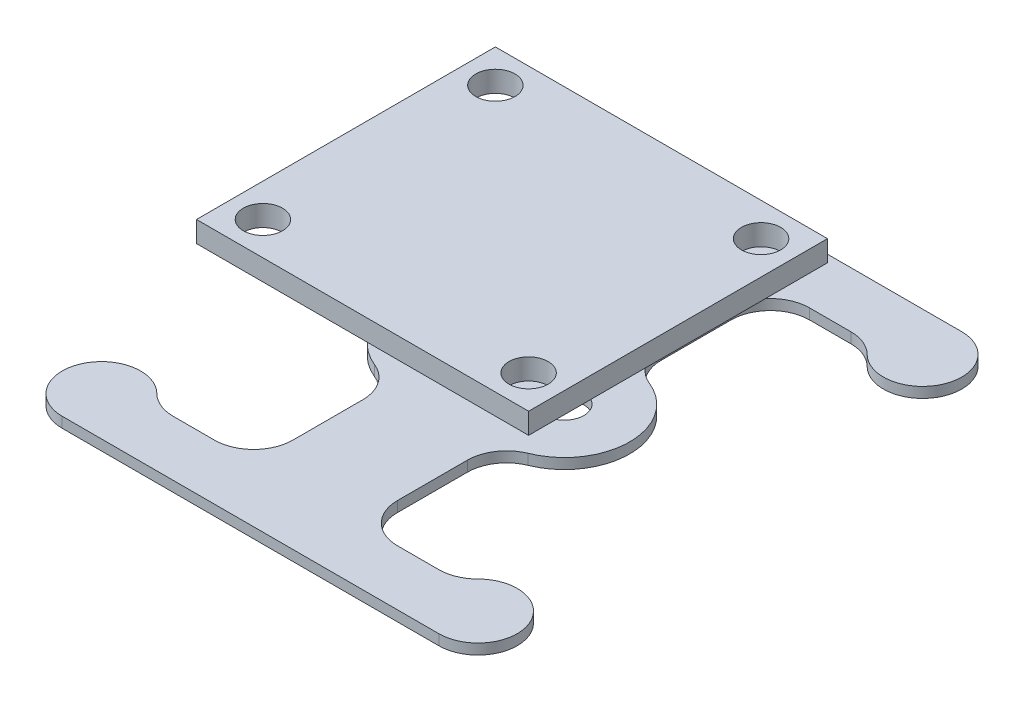
from build123d import *

# Parameters (mm, degrees)
SKETCH1_W           = 25.4
SKETCH1_H           = 22.86
SKETCH1_R           = 1.5
BOSS_EXTRUDE1_DEPTH = 1.6
SKETCH10_R          = 1.5
BOSS_EXTRUDE7_DEPTH = 0.8


with BuildPart() as part:
    # Sketch1 → Boss-Extrude1 (new body)
    with BuildSketch(Plane(origin=(0, 0, 0), x_dir=(1, 0, 0), z_dir=(0, 1, 0))):
        Rectangle(SKETCH1_W, SKETCH1_H)
        with Locations((-10.16, 8.89)):
            Circle(SKETCH1_R, mode=Mode.SUBTRACT)
        with Locations((10.16, 8.89)):
            Circle(SKETCH1_R, mode=Mode.SUBTRACT)
        with Locations((10.16, -8.89)):
            Circle(SKETCH1_R, mode=Mode.SUBTRACT)
        with Locations((-10.16, -8.89)):
            Circle(SKETCH1_R, mode=Mode.SUBTRACT)
    extrude(amount=BOSS_EXTRUDE1_DEPTH)


with BuildPart() as body_2:
    # Sketch10 → Boss-Extrude7 (new body)
    with BuildSketch(Plane(origin=(0, -8, 0), x_dir=(-1, 0, 0), z_dir=(0, -1, 0))):
        with BuildLine():
            Line((-4, 7.416198487), (-4, 12.757359313))
            ThreePointArc((-4, 12.757359313), (-4.878679656, 14.878679656), (-7, 15.757359313))
            Line((-7, 15.757359313), (-10.16, 15.757359313))
            ThreePointArc((-10.16, 15.757359313), (-11.308050297, 15.52899791), (-12.281320344, 14.878679656))
            ThreePointArc((-12.281320344, 14.878679656), (-17.174279285, 15.851949703), (-14.402640687, 20))
            Line((-14.402640687, 20), (14.402640687, 20))
            ThreePointArc((14.402640687, 20), (17.174279285, 15.851949703), (12.281320344, 14.878679656))
            ThreePointArc((12.281320344, 14.878679656), (11.308050297, 15.52899791), (10.16, 15.757359313))
            Line((10.16, 15.757359313), (7, 15.757359313))
            ThreePointArc((7, 15.757359313), (4.878679656, 14.878679656), (4, 12.757359313))
            Line((4, 12.757359313), (4, 7.416198487))
            ThreePointArc((4, 7.416198487), (4.512531407, 5.739147504), (5.875, 4.635124054))
            ThreePointArc((5.875, 4.635124054), (9, 0), (5.875, -4.635124054))
            ThreePointArc((5.875, -4.635124054), (4.512531407, -5.739147504), (4, -7.416198487))
            Line((4, -7.416198487), (4, -12.757359313))
            ThreePointArc((4, -12.757359313), (4.878679656, -14.878679656), (7, -15.757359313))
            Line((7, -15.757359313), (10.16, -15.757359313))
            ThreePointArc((10.16, -15.757359313), (11.308050297, -15.52899791), (12.281320344, -14.878679656))
            ThreePointArc((12.281320344, -14.878679656), (17.174279285, -15.851949703), (14.402640687, -20))
            Line((14.402640687, -20), (-14.402640687, -20))
            ThreePointArc((-14.402640687, -20), (-17.174279285, -15.851949703), (-12.281320344, -14.878679656))
            ThreePointArc((-12.281320344, -14.878679656), (-11.308050297, -15.52899791), (-10.16, -15.757359313))
            Line((-10.16, -15.757359313), (-7, -15.757359313))
            ThreePointArc((-7, -15.757359313), (-4.878679656, -14.878679656), (-4, -12.757359313))
            Line((-4, -12.757359313), (-4, -7.416198487))
            ThreePointArc((-4, -7.416198487), (-4.512531407, -5.739147504), (-5.875, -4.635124054))
            ThreePointArc((-5.875, -4.635124054), (-9, 0), (-5.875, 4.635124054))
            ThreePointArc((-5.875, 4.635124054), (-4.512531407, 5.739147504), (-4, 7.416198487))
        make_face()
        with Locations((-4, 0)):
            Circle(SKETCH10_R, mode=Mode.SUBTRACT)
        with Locations((4, 0)):
            Circle(SKETCH10_R, mode=Mode.SUBTRACT)
    extrude(amount=BOSS_EXTRUDE7_DEPTH)


solid = Compound([part.part, body_2.part])
